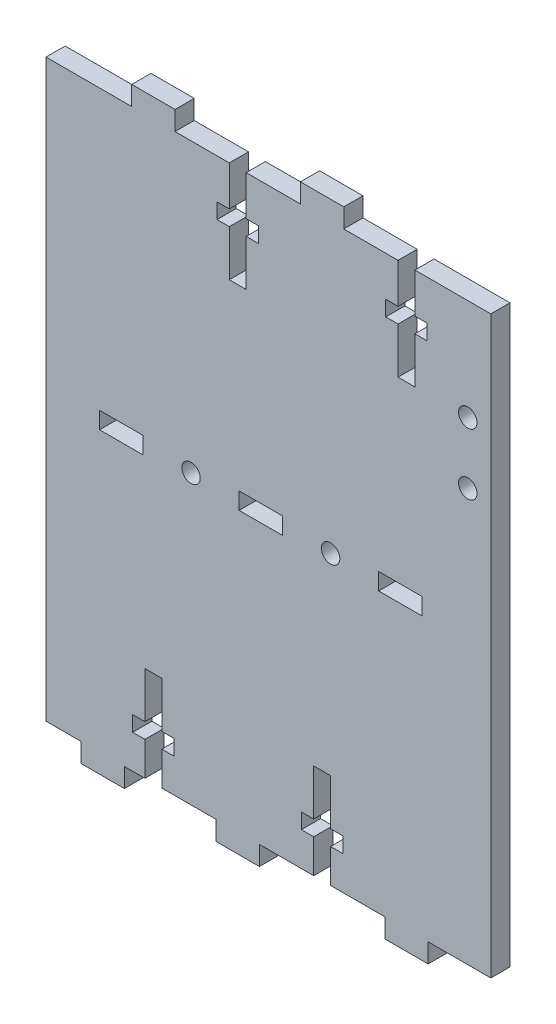
from build123d import *

# Parameters (mm, degrees)
BOSS_EXTRUDE1_DEPTH = 3.175
SKETCH4_R           = 1.524
CUT_EXTRUDE1_DEPTH  = 4.175
CUT_EXTRUDE2_DEPTH  = 4.175


with BuildPart() as part:
    # Sketch1 → Boss-Extrude1 (new body)
    with BuildSketch(Plane.XY):
        Polygon((-3.81, 95.25), (-3.81, 0), (2.00025, 0), (2.00025, -3.175), (9.17575, -3.175), (9.17575, 0), (12.573, 0), (12.573, 5.588), (10.541, 5.588), (10.541, 8.128), (12.573, 8.128), (12.573, 15.748), (15.367, 15.748), (15.367, 8.128), (17.399, 8.128), (17.399, 5.588), (15.367, 5.588), (15.367, 0), (24.35225, 0), (24.35225, -3.175), (31.52775, -3.175), (31.52775, 0), (40.513, 0), (40.513, 5.588), (38.481, 5.588), (38.481, 8.128), (40.513, 8.128), (40.513, 15.748), (43.307, 15.748), (43.307, 8.128), (45.339, 8.128), (45.339, 5.588), (43.307, 5.588), (43.307, 0), (52.29225, 0), (52.29225, -3.175), (59.46775, -3.175), (59.46775, 0), (69.85, 0), (69.85, 95.25), (57.277, 95.25), (57.277, 88.646), (59.309, 88.646), (59.309, 86.106), (57.277, 86.106), (57.277, 78.486), (54.483, 78.486), (54.483, 86.106), (52.451, 86.106), (52.451, 88.646), (54.483, 88.646), (54.483, 95.25), (45.49775, 95.25), (45.49775, 98.425), (38.32225, 98.425), (38.32225, 95.25), (29.337, 95.25), (29.337, 88.646), (31.369, 88.646), (31.369, 86.106), (29.337, 86.106), (29.337, 78.486), (26.543, 78.486), (26.543, 86.106), (24.511, 86.106), (24.511, 88.646), (26.543, 88.646), (26.543, 95.25), (17.55775, 95.25), (17.55775, 98.425), (10.38225, 98.425), (10.38225, 95.25), align=None)
    extrude(amount=BOSS_EXTRUDE1_DEPTH)

    # Sketch4 → Cut-Extrude1 (cut, through all)
    with BuildSketch(Plane.XY.offset(3.175)):
        with Locations((66.04, 68.326)):
            Circle(SKETCH4_R)
        with Locations((66.04, 78.486)):
            Circle(SKETCH4_R)
    extrude(amount=-CUT_EXTRUDE1_DEPTH, mode=Mode.SUBTRACT)

    # Sketch5 → Cut-Extrude2 (cut, through all)
    with BuildSketch(Plane.XY.offset(3.175)):
        Polygon((12.237024548, 46.228), (12.237024548, 49.022), (5.061524548, 49.022), (5.061524548, 47.625), (5.061524548, 46.228), align=None)
        with BuildLine():
            ThreePointArc((21.730274548, 47.625), (20.206274548, 49.149), (18.682274548, 47.625))
            Line((18.682274548, 47.625), (20.206274548, 47.625))
            Line((20.206274548, 47.625), (21.730274548, 47.625))
        make_face()
        with BuildLine():
            Line((20.206274548, 47.625), (18.682274548, 47.625))
            ThreePointArc((18.682274548, 47.625), (20.206274548, 46.101), (21.730274548, 47.625))
            Line((21.730274548, 47.625), (20.206274548, 47.625))
        make_face()
        Polygon((28.175524548, 46.228), (28.175524548, 47.625), (28.175524548, 49.022), (35.351024548, 49.022), (35.351024548, 46.228), align=None)
        with BuildLine():
            ThreePointArc((44.844274548, 47.625), (43.320274548, 49.149), (41.796274548, 47.625))
            Line((41.796274548, 47.625), (43.320274548, 47.625))
            Line((43.320274548, 47.625), (44.844274548, 47.625))
        make_face()
        with BuildLine():
            Line((43.320274548, 47.625), (41.796274548, 47.625))
            ThreePointArc((41.796274548, 47.625), (43.320274548, 46.101), (44.844274548, 47.625))
            Line((44.844274548, 47.625), (43.320274548, 47.625))
        make_face()
        Polygon((51.289524548, 46.228), (51.289524548, 47.625), (51.289524548, 49.022), (58.465024548, 49.022), (58.465024548, 46.228), align=None)
    extrude(amount=-CUT_EXTRUDE2_DEPTH, mode=Mode.SUBTRACT)


solid = part.part
